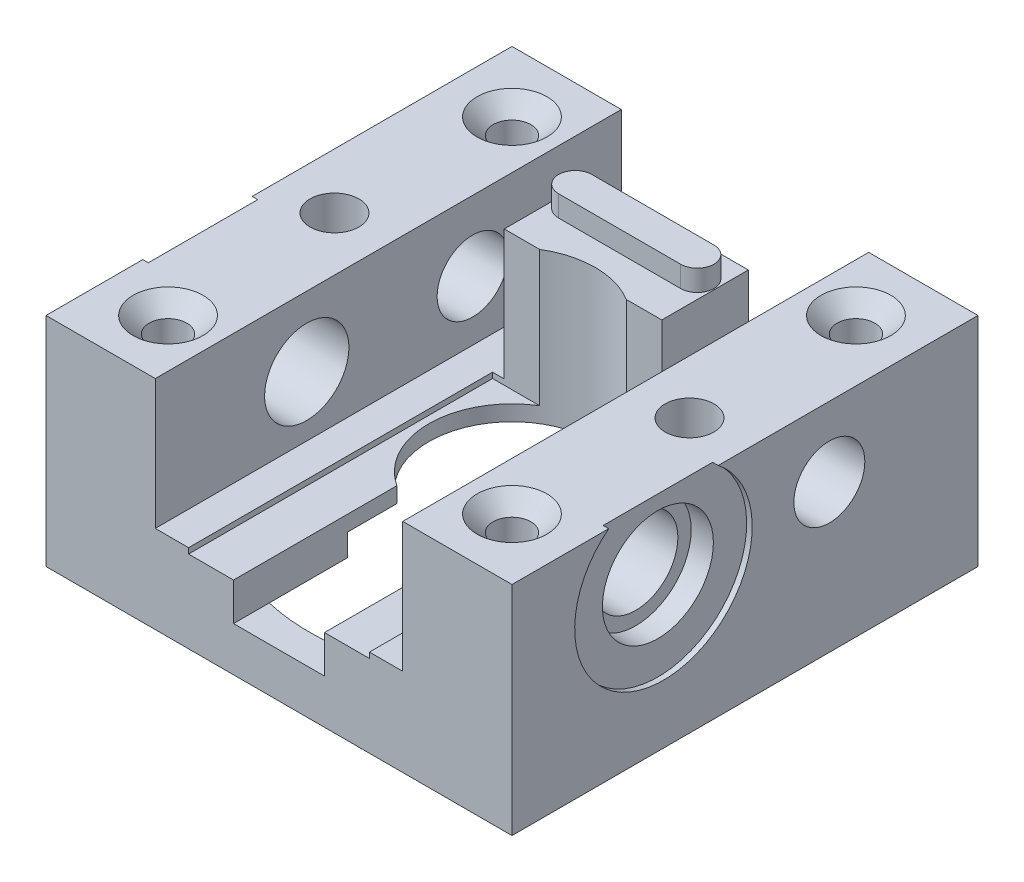
from build123d import *

# Parameters (mm, degrees)
CROQUIS3_W                                           = 42
CROQUIS3_H                                           = 42
SALIENTE_EXTRUIR1_DEPTH                              = 19.6
CROQUIS4_W                                           = 22.3
CROQUIS4_H                                           = 42
CROQUIS4_W_2                                         = 14.2
CROQUIS4_H_2                                         = 7.8
CORTAR_EXTRUIR1_DEPTH                                = 11.7
CROQUIS5_W                                           = 16.3
CROQUIS5_H                                           = 6.8
CROQUIS5_H_2                                         = 27.4
CORTAR_EXTRUIR2_DEPTH                                = 0.5
CORTAR_EXTRUIR3_START                                = -3.4
CORTAR_EXTRUIR3_DEPTH                                = 15.6
CROQUIS7_R                                           = 18.25
CORTAR_EXTRUIR4_DEPTH                                = 4
CROQUIS8_R                                           = 11.5
CORTAR_EXTRUIR5_DEPTH                                = 2
CROQUIS9_R                                           = 2.2
CORTAR_EXTRUIR6_DEPTH                                = 15.6
AVELLANADO_PARA_TORNILLO_CON_CABEZA_PLAN_D           = 3.4
AVELLANADO_PARA_TORNILLO_CON_CABEZA_PLAN_CSINK_D     = 6.3
AVELLANADO_PARA_TORNILLO_CON_CABEZA_PLAN_CSINK_ANGLE = 90
SALIENTE_EXTRUIR3_DEPTH                              = 1.9
CROQUIS13_R                                          = 8
CORTAR_EXTRUIR7_DEPTH                                = 0.5
CROQUIS14_R                                          = 5
CORTAR_EXTRUIR8_DEPTH                                = 2
DI_METRO_DE_TALADRO_7_6_7_6_1_D                      = 7.6
CROQUIS17_R                                          = 8
CORTAR_EXTRUIR9_DEPTH                                = 0.5
CROQUIS18_R                                          = 5
CORTAR_EXTRUIR10_DEPTH                               = 2
CROQUIS19_R                                          = 2.7
CORTAR_EXTRUIR11_DEPTH                               = 4.9
DI_METRO_DE_TALADRO_6_4_6_4_1_D                      = 6.4
DI_METRO_DE_TALADRO_6_4_6_4_1_DEPTH                  = 9.85
DI_METRO_DE_TALADRO_6_4_6_4_2_D                      = 6.4
DI_METRO_DE_TALADRO_6_4_6_4_2_DEPTH                  = 9.85


with BuildPart() as part:
    # Croquis3 → Saliente-Extruir1 (new body)
    with BuildSketch(Plane(origin=(0, 0, 0), x_dir=(1, 0, 0), z_dir=(0, 1, 0))):
        Rectangle(CROQUIS3_W, CROQUIS3_H)
    extrude(amount=-SALIENTE_EXTRUIR1_DEPTH)

    # Croquis4 → Cortar-Extruir1 (cut)
    with BuildSketch(Plane(origin=(0, 0, 0), x_dir=(1, 0, 0), z_dir=(0, 1, 0))):
        Rectangle(CROQUIS4_W, CROQUIS4_H)
        with Locations((0, 10.3)):
            Rectangle(CROQUIS4_W_2, CROQUIS4_H_2, mode=Mode.SUBTRACT)
    extrude(amount=-CORTAR_EXTRUIR1_DEPTH, mode=Mode.SUBTRACT)

    # Croquis5 → Cortar-Extruir2 (cut)
    with BuildSketch(Plane(origin=(0, -11.7, 0), x_dir=(1, 0, 0), z_dir=(0, 1, 0))):
        with Locations((0, 17.6)):
            Rectangle(CROQUIS5_W, CROQUIS5_H)
        with Locations((0, -7.3)):
            Rectangle(CROQUIS5_W, CROQUIS5_H_2)
    extrude(amount=-CORTAR_EXTRUIR2_DEPTH, mode=Mode.SUBTRACT)

    # Croquis6 → Cortar-Extruir3 (cut)
    with BuildSketch(Plane(origin=(0, -12.2, 0), x_dir=(1, 0, 0), z_dir=(0, 1, 0)).offset(CORTAR_EXTRUIR3_START)):
        with BuildLine():
            Line((4.1, -21), (4.1, -6.280127387))
            ThreePointArc((4.1, -6.280127387), (0, 7.5), (-4.1, -6.280127387))
            Line((-4.1, -6.280127387), (-4.1, -21))
            Line((-4.1, -21), (4.1, -21))
        make_face()
    extrude(amount=CORTAR_EXTRUIR3_DEPTH, mode=Mode.SUBTRACT)

    # Croquis7 → Cortar-Extruir4 (cut)
    with BuildSketch(Plane.XZ.offset(19.6)):
        Circle(CROQUIS7_R)
    extrude(amount=-CORTAR_EXTRUIR4_DEPTH, mode=Mode.SUBTRACT)

    # Croquis8 → Cortar-Extruir5 (cut)
    with BuildSketch(Plane.XZ.offset(15.6)):
        Circle(CROQUIS8_R)
    extrude(amount=-CORTAR_EXTRUIR5_DEPTH, mode=Mode.SUBTRACT)

    # Croquis9 → Cortar-Extruir6 (cut)
    with BuildSketch(Plane.XZ.offset(15.6)):
        with Locations((-16, 0)):
            Circle(CROQUIS9_R)
        with Locations((16, 0)):
            Circle(CROQUIS9_R)
    extrude(amount=-CORTAR_EXTRUIR6_DEPTH, mode=Mode.SUBTRACT)

    # Avellanado para tornillo con cabeza plana avellanada de M31 (through all)
    with Locations(Plane(origin=(0, 0, 0), x_dir=(1, 0, 0), z_dir=(0, 1, 0))):
        with Locations((-15.5, 15.5), (15.5, 15.5), (15.5, -15.5), (-15.5, -15.5)):
            CounterSinkHole(AVELLANADO_PARA_TORNILLO_CON_CABEZA_PLAN_D / 2, AVELLANADO_PARA_TORNILLO_CON_CABEZA_PLAN_CSINK_D / 2, counter_sink_angle=AVELLANADO_PARA_TORNILLO_CON_CABEZA_PLAN_CSINK_ANGLE)

    # Croquis12 → Saliente-Extruir3 (add)
    with BuildSketch(Plane(origin=(0, 0, 0), x_dir=(1, 0, 0), z_dir=(0, 1, 0))):
        with BuildLine():
            Line((-5.5, 12.7), (5.5, 12.7))
            ThreePointArc((5.5, 12.7), (7, 11.2), (5.5, 9.7))
            Line((5.5, 9.7), (-5.5, 9.7))
            ThreePointArc((-5.5, 9.7), (-7, 11.2), (-5.5, 12.7))
        make_face()
    extrude(amount=SALIENTE_EXTRUIR3_DEPTH)

    # Croquis13 → Cortar-Extruir7 (cut)
    with BuildSketch(Plane(origin=(21, 0, 0), x_dir=(0, 0, -1), z_dir=(1, 0, 0))):
        with Locations((-7.35, -6.3)):
            Circle(CROQUIS13_R)
    extrude(amount=-CORTAR_EXTRUIR7_DEPTH, mode=Mode.SUBTRACT)

    # Croquis14 → Cortar-Extruir8 (cut)
    with BuildSketch(Plane(origin=(20.5, 0, 0), x_dir=(0, 0, -1), z_dir=(1, 0, 0))):
        with Locations((-7.35, -6.3)):
            Circle(CROQUIS14_R)
    extrude(amount=-CORTAR_EXTRUIR8_DEPTH, mode=Mode.SUBTRACT)

    # Diámetro de taladro Ø7.6 (7.6)1 (through all)
    with Locations(Plane(origin=(18.5, 0, 0), x_dir=(0, 0, -1), z_dir=(1, 0, 0))):
        with Locations((-7.35, -6.3)):
            Hole(DI_METRO_DE_TALADRO_7_6_7_6_1_D / 2)

    # Croquis17 → Cortar-Extruir9 (cut)
    with BuildSketch(Plane.ZY.offset(21)):
        with Locations((7.35, -6.3)):
            Circle(CROQUIS17_R)
    extrude(amount=-CORTAR_EXTRUIR9_DEPTH, mode=Mode.SUBTRACT)

    # Croquis18 → Cortar-Extruir10 (cut)
    with BuildSketch(Plane.ZY.offset(20.5)):
        with Locations((7.35, -6.3)):
            Circle(CROQUIS18_R)
    extrude(amount=-CORTAR_EXTRUIR10_DEPTH, mode=Mode.SUBTRACT)

    # Croquis19 → Cortar-Extruir11 (cut)
    with BuildSketch(Plane(origin=(0, 0, -14.2), x_dir=(-1, 0, 0), z_dir=(0, 0, -1))):
        with Locations((4, -6.2)):
            Circle(CROQUIS19_R)
        with Locations((-4, -6.2)):
            Circle(CROQUIS19_R)
    extrude(amount=-CORTAR_EXTRUIR11_DEPTH, mode=Mode.SUBTRACT)

    # Diámetro de taladro Ø6.4 (6.4)1
    with Locations(Plane.ZY.offset(21)):
        with Locations((-7.6, -6.3)):
            Hole(DI_METRO_DE_TALADRO_6_4_6_4_1_D / 2, depth=DI_METRO_DE_TALADRO_6_4_6_4_1_DEPTH)

    # Diámetro de taladro Ø6.4 (6.4)2
    with Locations(Plane(origin=(21, 0, 0), x_dir=(0, 0, -1), z_dir=(1, 0, 0))):
        with Locations((7.6, -6.3)):
            Hole(DI_METRO_DE_TALADRO_6_4_6_4_2_D / 2, depth=DI_METRO_DE_TALADRO_6_4_6_4_2_DEPTH)


solid = part.part
